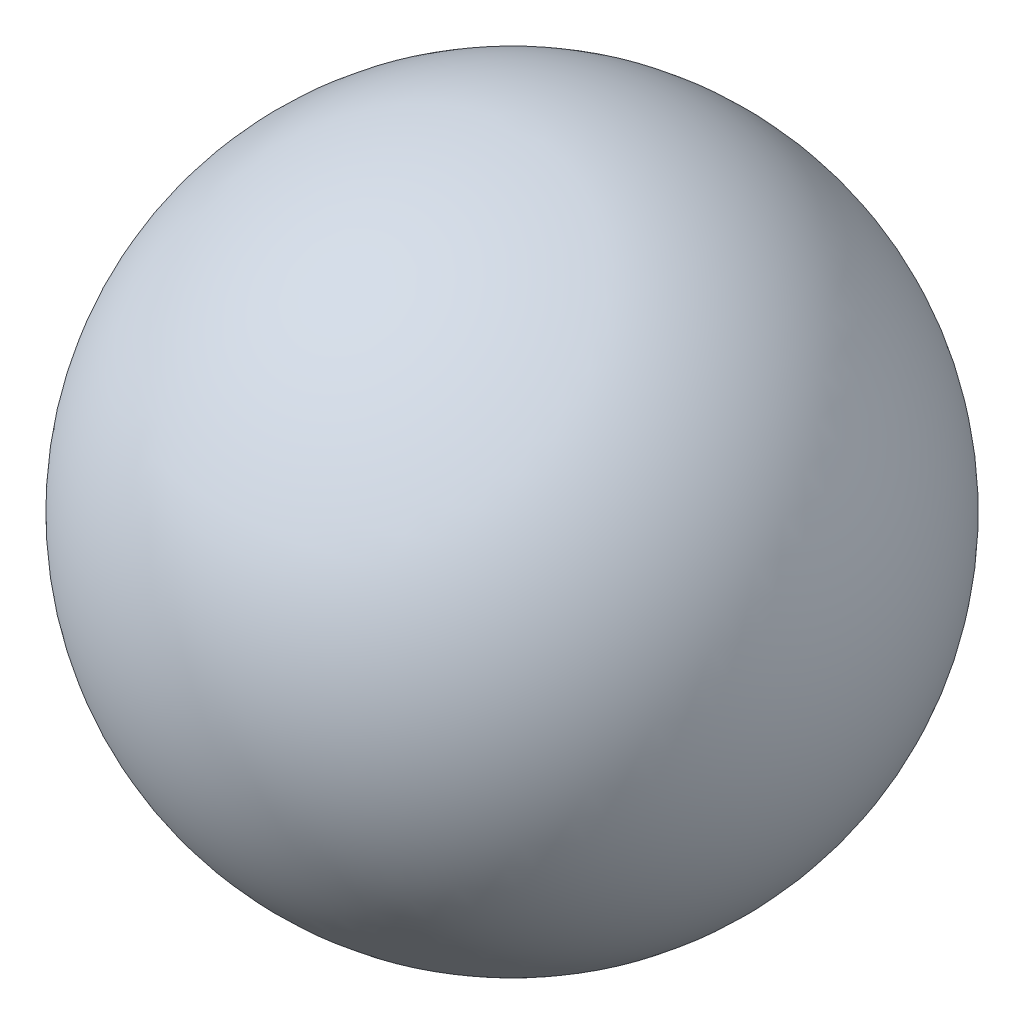
from build123d import *


with BuildPart() as part:
    # Sketch1 → Revolve1 (revolve)
    with BuildSketch(Plane.XY):
        with BuildLine():
            Line((0, 6.35), (0, -6.35))
            ThreePointArc((0, -6.35), (-6.35, 0), (0, 6.35))
        make_face()
    revolve(axis=Axis((0, 6.35, 0), (0, -1, 0)))


solid = part.part
